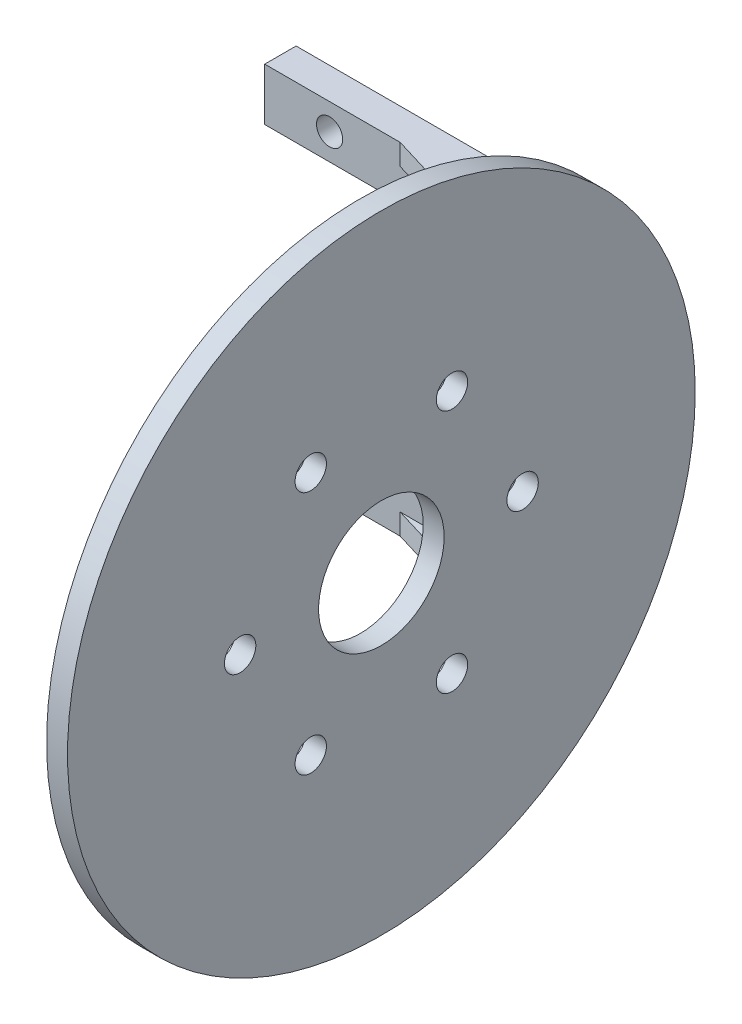
from build123d import *

# Parameters (mm, degrees)
SKETCH_1_W      = 12.4
SKETCH_1_H      = 5
SKETCH_1_R      = 1.25
SKETCH_1_W_2    = 5
SKETCH_1_H_2    = 11.3
EXTRUDE_1_DEPTH = 3
SKETCH_2_W      = 3
SKETCH_2_H      = 16.3
EXTRUDE_2_DEPTH = 12
EXTRUDE_3_DEPTH = 2
SKETCH_4_R      = 30
SKETCH_4_R_2    = 1.5
SKETCH_4_R_3    = 6
EXTRUDE_4_DEPTH = 2
FILLET_2_R      = 2


with BuildPart() as part:
    # Эскиз1 → Бобышка-Вытянуть1 (new body)
    with BuildSketch(Plane.XY):
        with Locations((0, 13.8)):
            Rectangle(SKETCH_1_W, SKETCH_1_H)
        with Locations((0, 13.8)):
            Circle(SKETCH_1_R, mode=Mode.SUBTRACT)
        with Locations((8.7, 13.8)):
            Rectangle(SKETCH_1_W_2, SKETCH_1_H)
        with Locations((8.7, 5.65)):
            Rectangle(SKETCH_1_W_2, SKETCH_1_H_2)
    extrude_1 = extrude(amount=EXTRUDE_1_DEPTH)

    # Эскиз2 → Бобышка-Вытянуть2 (add)
    with BuildSketch(Plane(origin=(11.2, 0, 0), x_dir=(0, 0, -1), z_dir=(1, 0, 0))):
        with Locations((-1.5, 8.15)):
            Rectangle(SKETCH_2_W, SKETCH_2_H)
    extrude_2 = extrude(amount=EXTRUDE_2_DEPTH)

    # Эскиз3 → Бобышка-Вытянуть3 (add)
    with BuildSketch(Plane(origin=(0, 16.3, 0), x_dir=(1, 0, 0), z_dir=(0, 1, 0))):
        Polygon((23.2, -8), (23.2, -3), (6.75, -3), align=None)
    extrude_3 = extrude(amount=-EXTRUDE_3_DEPTH)

    # Зеркальное отражение1: Бобышка-Вытянуть1, Бобышка-Вытянуть2, Бобышка-Вытянуть3 across plane
    add(extrude_1.mirror(Plane(origin=(0, 0, 3), x_dir=(0, 0, 1), z_dir=(0, -1, 0))))
    add(extrude_2.mirror(Plane(origin=(0, 0, 3), x_dir=(0, 0, 1), z_dir=(0, -1, 0))))
    add(extrude_3.mirror(Plane(origin=(0, 0, 3), x_dir=(0, 0, 1), z_dir=(0, -1, 0))))

    # Эскиз4 → Бобышка-Вытянуть4 (add)
    with BuildSketch(Plane(origin=(23.2, 0, 0), x_dir=(0, 0, -1), z_dir=(1, 0, 0))):
        with Locations((-23.25, 0)):
            Circle(SKETCH_4_R)
        with Locations((-30, -11.691342951)):
            Circle(SKETCH_4_R_2, mode=Mode.SUBTRACT)
        with Locations((-16.5, 11.691342951)):
            Circle(SKETCH_4_R_2, mode=Mode.SUBTRACT)
        with Locations((-9.75, 0)):
            Circle(SKETCH_4_R_2, mode=Mode.SUBTRACT)
        with Locations((-36.75, 0)):
            Circle(SKETCH_4_R_2, mode=Mode.SUBTRACT)
        with Locations((-16.5, -11.691342951)):
            Circle(SKETCH_4_R_2, mode=Mode.SUBTRACT)
        with Locations((-30, 11.691342951)):
            Circle(SKETCH_4_R_2, mode=Mode.SUBTRACT)
        with Locations((-23.25, 0)):
            Circle(SKETCH_4_R_3, mode=Mode.SUBTRACT)
        Polygon((-3, 14.3), (-3, -14.3), (-8, -14.3), (-8, -16.3), (0, -16.3), (0, 16.3), (-8, 16.3), (-8, 14.3), align=None, mode=Mode.SUBTRACT)
        Polygon((-8, 14.3), (-3, 14.3), (-3, -14.3), (-8, -14.3), (-8, -16.3), (0, -16.3), (0, 16.3), (-8, 16.3), align=None)
    extrude(amount=EXTRUDE_4_DEPTH)

    # Скругление2
    fillet_2_edges = [part.edges().sort_by_distance(p)[0] for p in [
        (23.2, 16.3, 4),
        (23.2, 0, 3),
        (23.2, 15.3, 8),
        (23.2, 14.3, 5.5),
        (23.2, -16.3, 4),
        (23.2, -14.3, 5.5),
        (23.2, -15.3, 8),
    ]]
    fillet(fillet_2_edges, radius=FILLET_2_R)


solid = part.part
